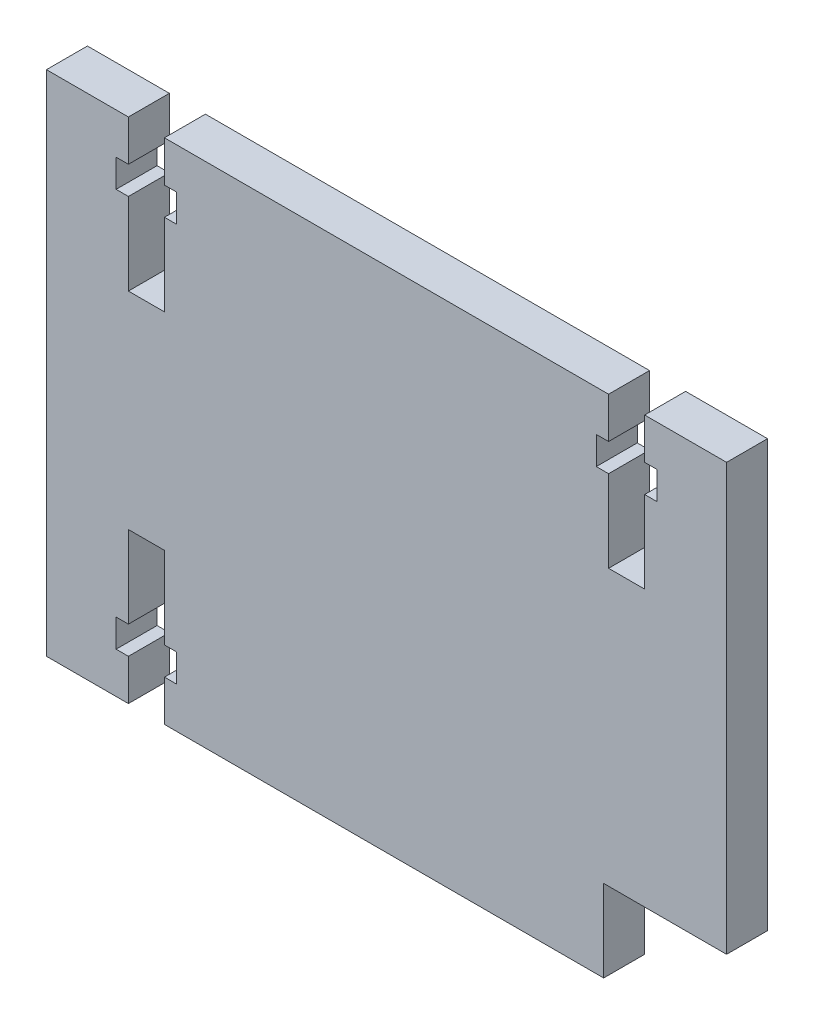
from build123d import *

# Parameters (mm, degrees)
SKETCH1_W           = 83
SKETCH1_H           = 62
BOSS_EXTRUDE1_DEPTH = 5
SKETCH2_W           = 15
SKETCH2_H           = 10
CUT_EXTRUDE1_DEPTH  = 10
CUT_EXTRUDE2_DEPTH  = 5


with BuildPart() as part:
    # Sketch1 → Boss-Extrude1 (new body)
    with BuildSketch(Plane.XY):
        Rectangle(SKETCH1_W, SKETCH1_H)
    extrude(amount=BOSS_EXTRUDE1_DEPTH)

    # Sketch2 → Cut-Extrude1 (cut)
    with BuildSketch(Plane.XY.offset(5)):
        with Locations((34, -26)):
            Rectangle(SKETCH2_W, SKETCH2_H)
    extrude(amount=-CUT_EXTRUDE1_DEPTH, mode=Mode.SUBTRACT)

    # Sketch3 → Cut-Extrude2 (cut)
    with BuildSketch(Plane.XY.offset(5)):
        Polygon((-27.1, 22.6), (-27.1, 12.6), (-31.5, 12.6), (-31.5, 22.6), (-33, 22.6), (-33, 26), (-31.5, 26), (-31.5, 31), (-27.1, 31), (-27.1, 26), (-25.6, 26), (-25.6, 22.6), align=None)
        Polygon((31.5, 12.6), (31.5, 22.6), (33, 22.6), (33, 26), (31.5, 26), (31.5, 31), (27.1, 31), (27.1, 26), (25.6, 26), (25.6, 22.6), (27.1, 22.6), (27.1, 12.6), align=None)
        Polygon((-31.5, -12.6), (-31.5, -22.6), (-33, -22.6), (-33, -26), (-31.5, -26), (-31.5, -31), (-27.1, -31), (-27.1, -26), (-25.6, -26), (-25.6, -22.6), (-27.1, -22.6), (-27.1, -12.6), align=None)
    extrude(amount=-CUT_EXTRUDE2_DEPTH, mode=Mode.SUBTRACT)


solid = part.part
